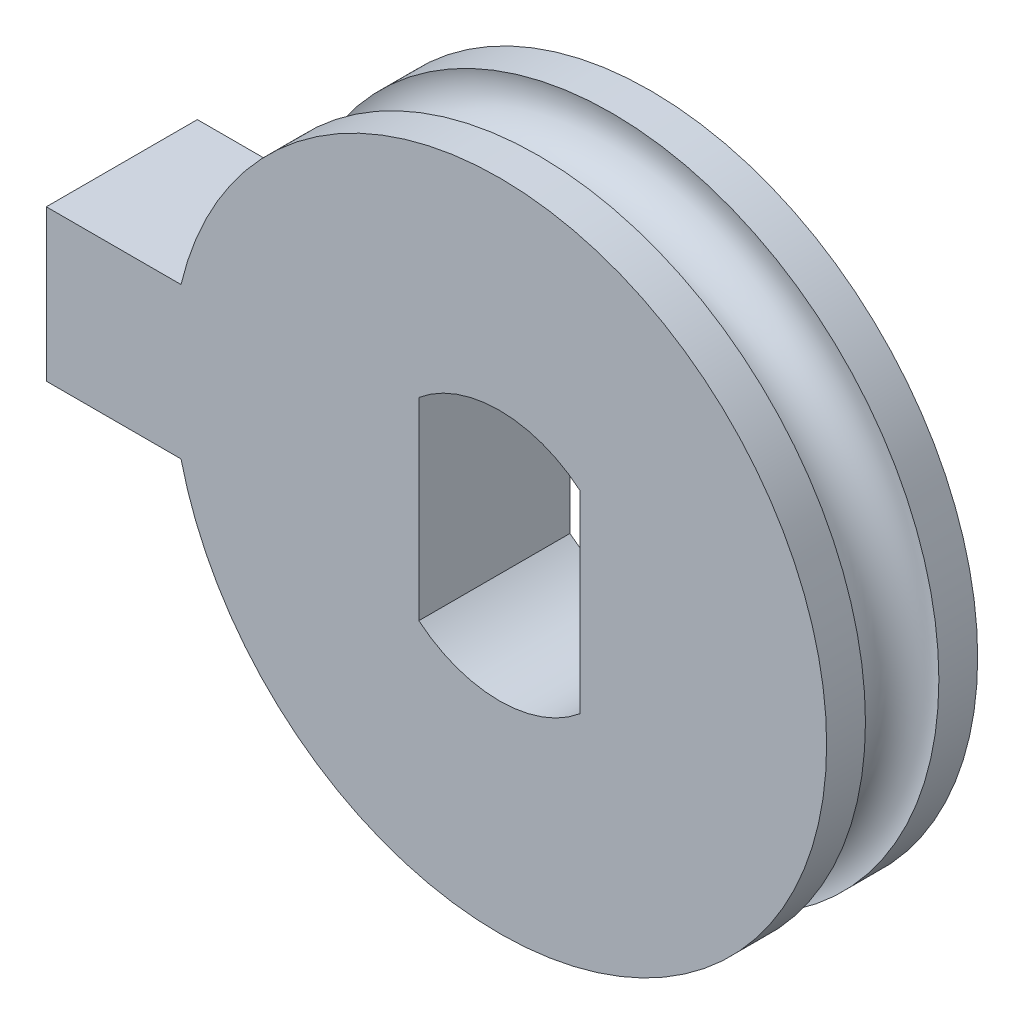
from build123d import *

# Parameters (mm, degrees)
EXTRUDE_1_DEPTH = 3
SKETCH_4_R      = 0.75


with BuildPart() as part:
    # Эскиз1 → Бобышка-Вытянуть1 (new body)
    with BuildSketch(Plane.XY):
        with BuildLine():
            Line((-9, 1.5), (-6.32455532, 1.5))
            ThreePointArc((-6.32455532, 1.5), (6.5, 0), (-6.32455532, -1.5))
            Line((-6.32455532, -1.5), (-9, -1.5))
            Line((-9, -1.5), (-9, 1.5))
        make_face()
        with BuildLine():
            Line((-1.6, 0), (-1.6, 1.92045554))
            ThreePointArc((-1.6, 1.92045554), (0, 2.499629869), (1.6, 1.92045554))
            Line((1.6, 1.92045554), (1.6, -1.92045554))
            ThreePointArc((1.6, -1.92045554), (0, -2.499629869), (-1.6, -1.92045554))
            Line((-1.6, -1.92045554), (-1.6, 0))
        make_face(mode=Mode.SUBTRACT)
    extrude(amount=EXTRUDE_1_DEPTH)

    # Эскиз4 → Вырез-Повернуть1 (revolve, cut)
    with BuildSketch(Plane(origin=(0, 0, 0), x_dir=(-1, 0, 0), z_dir=(0, -1, 0))):
        with Locations((6.32455532, -1.5)):
            Circle(SKETCH_4_R)
    revolve(axis=Axis((0, 0, 0), (0, 0, -1)), mode=Mode.SUBTRACT)


solid = part.part
